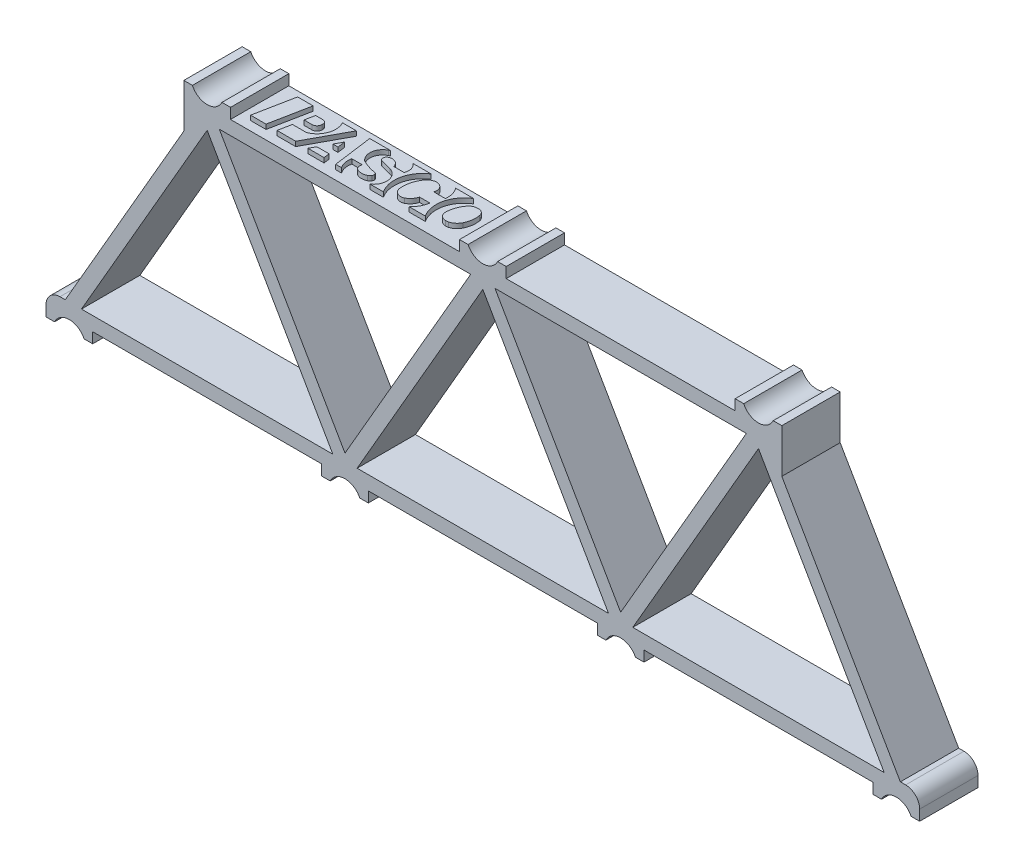
from build123d import *

# Parameters (mm, degrees)
BOSS_EXTRUDE1_DEPTH  = 3.175
BOSS_EXTRUDE2_DEPTH  = 3.175
BOSS_EXTRUDE3_START  = -3.175
BOSS_EXTRUDE3_DEPTH  = 6.35
FILLET1_R            = 1.524
FILLET1_OF_MIRROR1_R = 1.524
BOSS_EXTRUDE4_DEPTH  = 0.508


with BuildPart() as part:
    # Sketch1 → Boss-Extrude1 (new body, symmetric)
    with BuildSketch(Plane.XY):
        Polygon((-46.319822715, -26.742762114), (-30.439940905, 0.762), (0, 0.762), (30.439940905, 0.762), (46.319822715, -26.742762114), (15, -26.742762114), (-15, -26.742762114), align=None)
        Polygon((-43.680177285, -25.218762114), (-30, -1.524), (-16.319822715, -25.218762114), align=None, mode=Mode.SUBTRACT)
        Polygon((-28.680177285, -0.762), (-15, -24.456762114), (-1.319822715, -0.762), align=None, mode=Mode.SUBTRACT)
        Polygon((-13.680177285, -25.218762114), (0, -1.524), (13.680177285, -25.218762114), align=None, mode=Mode.SUBTRACT)
        Polygon((1.319822715, -0.762), (15, -24.456762114), (28.680177285, -0.762), align=None, mode=Mode.SUBTRACT)
        Polygon((16.319822715, -25.218762114), (30, -1.524), (43.680177285, -25.218762114), align=None, mode=Mode.SUBTRACT)
    extrude(amount=BOSS_EXTRUDE1_DEPTH, both=True)

    # Sketch2 → Boss-Extrude2 (add, symmetric)
    with BuildSketch(Plane.XY):
        with BuildLine():
            Line((-46.606437051, -27.885762114), (-47.54, -27.885762114))
            Line((-47.54, -27.885762114), (-47.54, -25.218762114))
            Line((-47.54, -25.218762114), (-42.46, -25.218762114))
            Line((-42.46, -25.218762114), (-42.46, -27.885762114))
            Line((-42.46, -27.885762114), (-43.393562949, -27.885762114))
            ThreePointArc((-43.393562949, -27.885762114), (-45, -26.869762114), (-46.606437051, -27.885762114))
        make_face()
        with BuildLine():
            Line((-27.46, 0.762), (-30.439940905, 0.762))
            Line((-30.439940905, 0.762), (-32.54, -2.875409051))
            Line((-32.54, -2.875409051), (-32.54, 0.762))
            Line((-32.54, 0.762), (-32.54, 1.905))
            Line((-32.54, 1.905), (-31.606437051, 1.905))
            ThreePointArc((-31.606437051, 1.905), (-30, 0.889), (-28.393562949, 1.905))
            Line((-28.393562949, 1.905), (-27.46, 1.905))
            Line((-27.46, 1.905), (-27.46, 0.762))
        make_face()
        with BuildLine():
            Line((-16.606437051, -27.885762114), (-17.54, -27.885762114))
            Line((-17.54, -27.885762114), (-17.54, -26.742762114))
            Line((-17.54, -26.742762114), (-12.46, -26.742762114))
            Line((-12.46, -26.742762114), (-12.46, -27.885762114))
            Line((-12.46, -27.885762114), (-13.393562949, -27.885762114))
            ThreePointArc((-13.393562949, -27.885762114), (-15, -26.869762114), (-16.606437051, -27.885762114))
        make_face()
    boss_extrude2 = extrude(amount=BOSS_EXTRUDE2_DEPTH, both=True)

    # Sketch3 → Boss-Extrude3 (add)
    with BuildSketch(Plane.XY.offset(BOSS_EXTRUDE3_START)):
        with BuildLine():
            Line((1.606437051, 1.905), (2.54, 1.905))
            Line((2.54, 1.905), (2.54, 0.762))
            Line((2.54, 0.762), (-2.54, 0.762))
            Line((-2.54, 0.762), (-2.54, 1.905))
            Line((-2.54, 1.905), (-1.606437051, 1.905))
            ThreePointArc((-1.606437051, 1.905), (0, 0.889), (1.606437051, 1.905))
        make_face()
    extrude(amount=BOSS_EXTRUDE3_DEPTH)

    # Fillet1
    fillet1_edges = [part.edges().sort_by_distance(p)[0] for p in [
        (-47.54, -25.218762114, 0),
    ]]
    fillet(fillet1_edges, radius=FILLET1_R)

    # Mirror1: Boss-Extrude2 across plane
    add(boss_extrude2.mirror(Plane(origin=(0, 0, 0), x_dir=(0, 0, 1), z_dir=(1, 0, 0))))

    # Fillet1 of Mirror1
    fillet1_of_mirror1_edges = [part.edges().sort_by_distance(p)[0] for p in [
        (47.54, -25.218762114, 0),
    ]]
    fillet(fillet1_of_mirror1_edges, radius=FILLET1_OF_MIRROR1_R)

    # Sketch4 → Boss-Extrude4 (add)
    with BuildSketch(Plane(origin=(30.341470111, 0.762, -10.998323426), x_dir=(-1, 0, 0), z_dir=(0, 1, 0))):
        Polygon((55.766638301, 8.903049935), (54.0821519, 8.903049935), (54.924395101, 13.184452869), (56.608881501, 13.184452869), align=None)
        with BuildLine():
            Line((49.373679321, 8.903049935), (51.695796166, 13.184452869))
            Line((51.695796166, 13.184452869), (53.731217234, 13.184452869))
            Line((53.731217234, 13.184452869), (53.455071922, 11.780714202))
            Line((53.455071922, 11.780714202), (52.044845481, 11.780714202))
            ThreePointArc((52.044845481, 11.780714202), (51.895660414, 11.763021636), (51.754751921, 11.710925494))
            ThreePointArc((51.754751921, 11.710925494), (50.74099205, 10.52746368), (50.853552966, 8.973236868))
            Line((50.853552966, 8.973236868), (50.888554794, 8.903049935))
            Line((50.888554794, 8.903049935), (49.373679321, 8.903049935))
        make_face()
        with BuildLine():
            Line((47.344206299, 13.184452869), (47.92473551, 8.903049935))
            Line((47.92473551, 8.903049935), (45.657455804, 8.903049935))
            Line((45.657455804, 8.903049935), (45.800093765, 8.973236868))
            ThreePointArc((45.800093765, 8.973236868), (46.559919921, 9.999679495), (46.16385217, 11.213784347))
            ThreePointArc((46.16385217, 11.213784347), (46.087708374, 11.278047887), (46.002485287, 11.329668676))
            ThreePointArc((46.002485287, 11.329668676), (45.241879319, 11.641820064), (44.44239948, 11.833632247))
            ThreePointArc((44.44239948, 11.833632247), (44.321830206, 11.897125178), (44.264573877, 12.020777977))
            ThreePointArc((44.264573877, 12.020777977), (44.273299822, 12.151811254), (44.326168164, 12.272022736))
            ThreePointArc((44.326168164, 12.272022736), (44.436687002, 12.409847066), (44.584321098, 12.50687352))
            ThreePointArc((44.584321098, 12.50687352), (45.07356558, 12.617554773), (45.566896159, 12.526805434))
            ThreePointArc((45.566896159, 12.526805434), (45.796502387, 12.340831934), (45.882880346, 12.05826511))
            Line((45.882880346, 12.05826511), (45.882880346, 11.780714202))
            Line((45.882880346, 11.780714202), (46.993271632, 11.780714202))
            ThreePointArc((46.993271632, 11.780714202), (47.00184458, 12.512372899), (46.712523898, 13.184452869))
            Line((46.712523898, 13.184452869), (47.344206299, 13.184452869))
        make_face()
        with BuildLine():
            Line((52.362572033, 10.727910202), (53.247962938, 10.727910202))
            Line((53.247962938, 10.727910202), (53.040853955, 9.675106202))
            Line((53.040853955, 9.675106202), (52.224130208, 9.675106202))
            ThreePointArc((52.224130208, 9.675106202), (51.949800938, 9.788737106), (51.836170033, 10.063066377))
            Line((51.836170033, 10.063066377), (51.836170033, 10.201508202))
            ThreePointArc((51.836170033, 10.201508202), (51.990349609, 10.573730626), (52.362572033, 10.727910202))
        make_face()
        Polygon((48.958505766, 10.596309702), (48.845492907, 11.429779536), (49.410557201, 11.429779536), align=None)
        Polygon((48.607571099, 13.184452869), (50.362244433, 13.184452869), (50.019637029, 12.552770469), (48.69322295, 12.552770469), align=None)
        with BuildLine():
            Line((43.093358174, 9.007864255), (43.203837606, 8.897384823))
            Line((43.203837606, 8.897384823), (41.238603472, 8.897384823))
            ThreePointArc((41.238603472, 8.897384823), (42.59037643, 10.850382179), (42.150373231, 13.184452869))
            Line((42.150373231, 13.184452869), (43.624298831, 13.184452869))
            ThreePointArc((43.624298831, 13.184452869), (42.976922737, 12.00046329), (43.609533036, 10.808518937))
            ThreePointArc((43.609533036, 10.808518937), (43.801404112, 10.703005905), (44.00849344, 10.63186155))
            Line((44.00849344, 10.63186155), (45.137184548, 10.349688773))
            ThreePointArc((45.137184548, 10.349688773), (45.325274084, 10.217067986), (45.375126192, 9.992388851))
            ThreePointArc((45.375126192, 9.992388851), (45.276758726, 9.771226443), (45.079326395, 9.631192719))
            ThreePointArc((45.079326395, 9.631192719), (44.392498989, 9.682709209), (43.976922089, 10.231964773))
            Line((43.976922089, 10.231964773), (42.853931155, 10.231964773))
            ThreePointArc((42.853931155, 10.231964773), (42.786913393, 9.583390951), (43.093358174, 9.007864255))
        make_face()
        with BuildLine():
            Line((38.57083963, 8.903049935), (36.605605496, 8.903049935))
            ThreePointArc((36.605605496, 8.903049935), (38.014670833, 10.833118693), (37.588222563, 13.184452869))
            Line((37.588222563, 13.184452869), (39.342895896, 13.184452869))
            ThreePointArc((39.342895896, 13.184452869), (38.831372076, 12.513225905), (38.57083963, 11.710527269))
            Line((38.57083963, 11.710527269), (39.693830563, 11.710527269))
            ThreePointArc((39.693830563, 11.710527269), (39.959617235, 12.233880985), (40.415270694, 12.603910164))
            ThreePointArc((40.415270694, 12.603910164), (41.166876497, 12.593701608), (41.591788981, 11.973649288))
            ThreePointArc((41.591788981, 11.973649288), (41.543037796, 10.949193829), (41.155213354, 9.999731945))
            ThreePointArc((41.155213354, 9.999731945), (40.782487914, 9.571566118), (40.251107207, 9.371854393))
            ThreePointArc((40.251107207, 9.371854393), (39.531077174, 9.674914925), (39.41308283, 10.447162469))
            Line((39.41308283, 10.447162469), (38.149718029, 10.447162469))
            ThreePointArc((38.149718029, 10.447162469), (38.201808334, 9.631886976), (38.57083963, 8.903049935))
        make_face()
        with BuildLine():
            Line((35.48104333, 9.602571887), (35.356873428, 9.602571887))
            ThreePointArc((35.356873428, 9.602571887), (34.923728887, 9.759646665), (34.691948891, 10.157848515))
            ThreePointArc((34.691948891, 10.157848515), (34.675735454, 10.986379145), (34.920455715, 11.778110082))
            ThreePointArc((34.920455715, 11.778110082), (35.261440878, 12.213116508), (35.747757566, 12.475790357))
            ThreePointArc((35.747757566, 12.475790357), (35.911443016, 12.505405638), (36.077655631, 12.511990293))
            ThreePointArc((36.077655631, 12.511990293), (36.647671195, 12.253324316), (36.864077445, 11.665962276))
            ThreePointArc((36.864077445, 11.665962276), (36.699639375, 10.801331502), (36.294750409, 10.019864179))
            ThreePointArc((36.294750409, 10.019864179), (35.938277424, 9.712977507), (35.48104333, 9.602571887))
        make_face()
    extrude(amount=BOSS_EXTRUDE4_DEPTH)


solid = part.part
